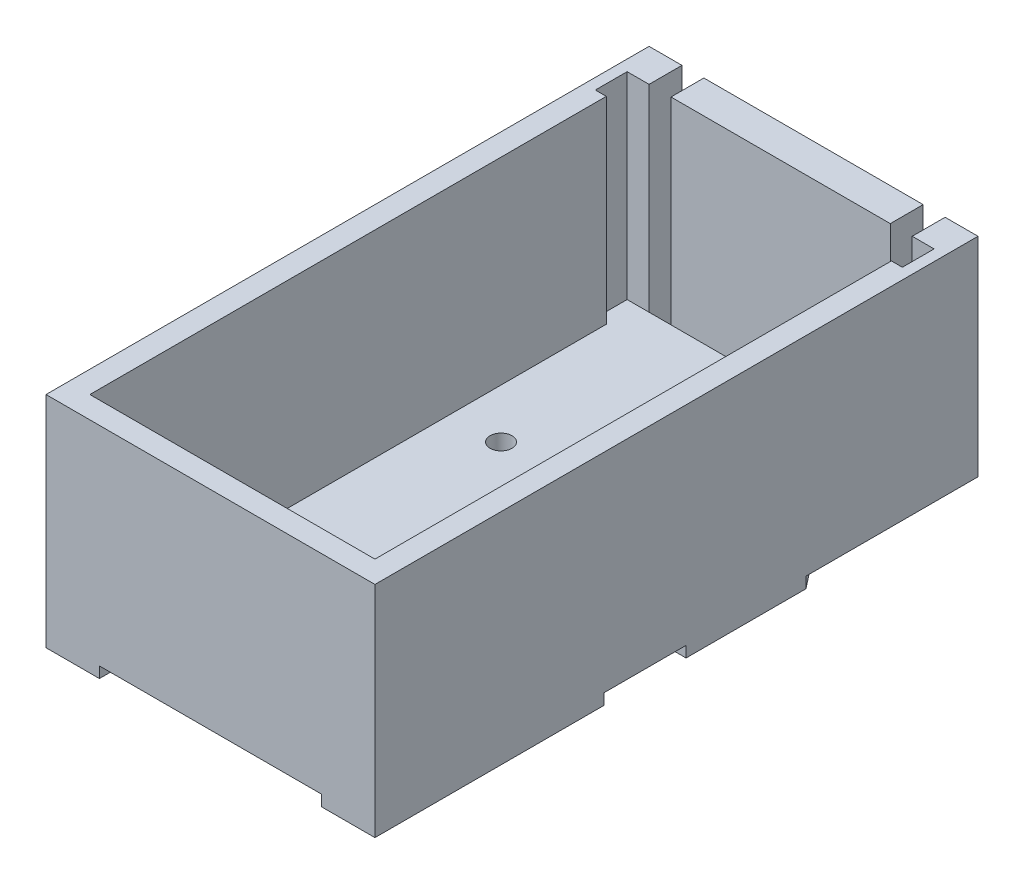
from build123d import *

# Parameters (mm, degrees)
SKETCH1_W           = 30
SKETCH1_H           = 55
BOSS_EXTRUDE1_DEPTH = 20
CUT_EXTRUDE1_DEPTH  = 18
SKETCH3_W           = 2
SKETCH3_H           = 3
CUT_EXTRUDE2_DEPTH  = 21
SKETCH4_W           = 7
SKETCH4_H           = 16
CUT_EXTRUDE3_DEPTH  = 1
SKETCH5_R           = 1
CUT_EXTRUDE4_DEPTH  = 21
CUT_EXTRUDE5_DEPTH  = 1


with BuildPart() as part:
    # Sketch1 → Boss-Extrude1 (new body)
    with BuildSketch(Plane(origin=(0, 0, 0), x_dir=(1, 0, 0), z_dir=(0, 1, 0))):
        with Locations((15, 27.5)):
            Rectangle(SKETCH1_W, SKETCH1_H)
    extrude(amount=BOSS_EXTRUDE1_DEPTH)

    # Sketch2 → Cut-Extrude1 (cut)
    with BuildSketch(Plane(origin=(0, 20, 0), x_dir=(-1, 0, 0), z_dir=(0, 1, 0))):
        Polygon((-29, -52), (-1, -52), (-1, -49.101557188), (-2, -49.101557188), (-2, -2), (-28, -2), (-28, -49.101557188), (-29, -49.101557188), align=None)
    extrude(amount=-CUT_EXTRUDE1_DEPTH, mode=Mode.SUBTRACT)

    # Sketch3 → Cut-Extrude2 (cut, through all)
    with BuildSketch(Plane(origin=(0, 20, 0), x_dir=(-1, 0, 0), z_dir=(0, 1, 0))):
        with Locations((-4, -53.5)):
            Rectangle(SKETCH3_W, SKETCH3_H)
        with Locations((-26, -53.5)):
            Rectangle(SKETCH3_W, SKETCH3_H)
    extrude(amount=-CUT_EXTRUDE2_DEPTH, mode=Mode.SUBTRACT)

    # Sketch4 → Cut-Extrude3 (cut)
    with BuildSketch(Plane(origin=(0, 0, -55), x_dir=(-1, 0, 0), z_dir=(0, 0, -1))):
        with Locations((-19.5, 10)):
            Rectangle(SKETCH4_W, SKETCH4_H)
        with Locations((-10.5, 10)):
            Rectangle(SKETCH4_W, SKETCH4_H)
    extrude(amount=-CUT_EXTRUDE3_DEPTH, mode=Mode.SUBTRACT)

    # Sketch5 → Cut-Extrude4 (cut, through all)
    with BuildSketch(Plane.XZ):
        with Locations((6.5, -14)):
            Circle(SKETCH5_R)
        with Locations((23.5, -14)):
            Circle(SKETCH5_R)
        with Locations((6.5, -35)):
            Circle(SKETCH5_R)
        with Locations((23.5, -35)):
            Circle(SKETCH5_R)
    extrude(amount=-CUT_EXTRUDE4_DEPTH, mode=Mode.SUBTRACT)

    # Sketch6 → Cut-Extrude5 (cut)
    with BuildSketch(Plane.XZ):
        Polygon((4.871763373, 0), (4.871763373, -2.932893163), (7.8857023, -2.932893163), (7.8857023, -12.114893151), (12.091198477, -12.114893151), (12.091198477, -13.867183225), (17.908801523, -13.867183225), (17.908801523, -12.114893151), (22.1142977, -12.114893151), (22.1142977, -2.932893163), (25.128236627, -2.932893163), (25.128236627, 0), align=None)
        Polygon((0, -20.87634352), (3.680206122, -20.87634352), (3.680206122, -22.698725197), (6.834328255, -22.698725197), (6.834328255, -20.87634352), (23.165671745, -20.87634352), (23.165671745, -22.698725197), (26.319793878, -22.698725197), (26.319793878, -20.87634352), (30, -20.87634352), (30, -28.376145037), (26.319793878, -28.376145037), (26.319793878, -26.203305345), (23.165671745, -26.203305345), (23.165671745, -28.376145037), (6.834328255, -28.376145037), (6.834328255, -26.203305345), (3.680206122, -26.203305345), (3.680206122, -28.376145037), (0, -28.376145037), align=None)
        Polygon((0, -39.310435098), (3.680206122, -44.006572497), (5.712862608, -44.006572497), (6.834328255, -42.885106849), (6.834328255, -39.801076319), (23.165671745, -39.801076319), (23.165671745, -42.885106849), (24.287137392, -44.006572497), (26.319793878, -44.006572497), (30, -39.310435098), (30, -55), (28.159896939, -55), (28.159896939, -51.43628241), (1.840103061, -51.43628241), (1.840103061, -55), (0, -55), align=None)
    extrude(amount=-CUT_EXTRUDE5_DEPTH, mode=Mode.SUBTRACT)


solid = part.part
